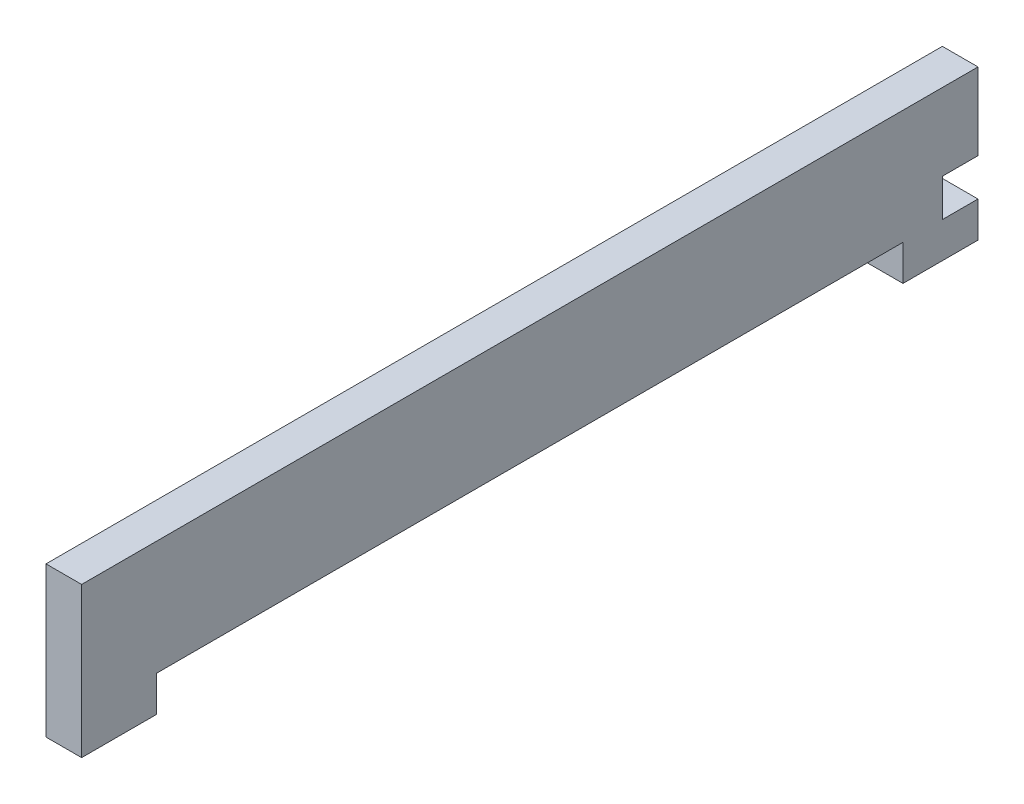
from build123d import *

# Parameters (mm, degrees)
BOSS_EXTRUDE1_DEPTH = 4.75
SKETCH2_W           = 4.75
SKETCH2_H           = 5
CUT_EXTRUDE1_DEPTH  = 4.75


with BuildPart() as part:
    # Sketch1 → Boss-Extrude1 (new body)
    with BuildSketch(Plane(origin=(0, 0, 0), x_dir=(0, 0, -1), z_dir=(1, 0, 0))):
        Polygon((109.5, 0), (119.5, 0), (119.5, 20), (0, 20), (0, 0), (10, 0), (10, 4.75), (109.5, 4.75), align=None)
    extrude(amount=BOSS_EXTRUDE1_DEPTH)

    # Sketch2 → Cut-Extrude1 (cut)
    with BuildSketch(Plane(origin=(4.75, 0, 0), x_dir=(0, 0, -1), z_dir=(1, 0, 0))):
        with Locations((117.125, 7.25)):
            Rectangle(SKETCH2_W, SKETCH2_H)
    extrude(amount=-CUT_EXTRUDE1_DEPTH, mode=Mode.SUBTRACT)


solid = part.part
